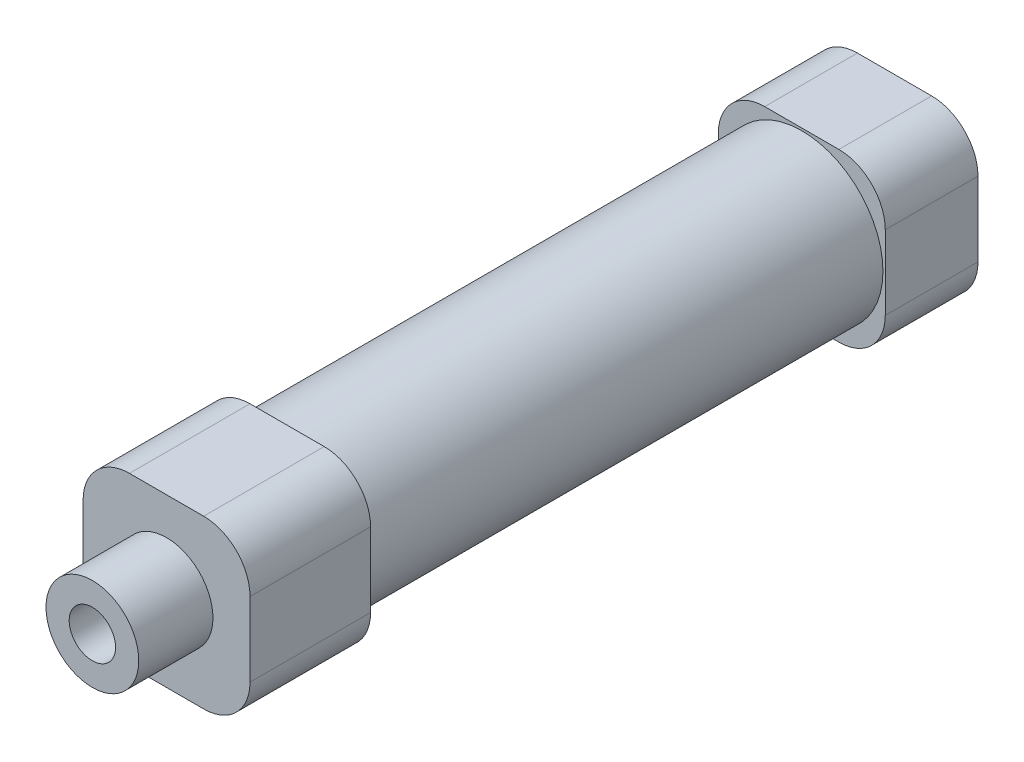
from build123d import *

# Parameters (mm, degrees)
SKETCH_1_W          = 18
SKETCH_1_H          = 18
EXTRUDE_1_DEPTH     = 10
SKETCH_2_R          = 8.75
EXTRUDE_2_DEPTH     = 55.5
SKETCH_3_W          = 18
SKETCH_3_H          = 18
EXTRUDE_3_DEPTH     = 13
SKETCH_4_R          = 5
EXTRUDE_4_DEPTH     = 8
SKETCH_5_R          = 2.5
CUT_EXTRUDE_1_DEPTH = 85.5
FILLET_1_R          = 5
CUT_EXTRUDE_2_REACH = 20
SKETCH_6_R          = 2.5


with BuildPart() as part:
    # 草图1 → 凸台-拉伸1 (new body)
    with BuildSketch(Plane.XY):
        Rectangle(SKETCH_1_W, SKETCH_1_H)
    extrude(amount=EXTRUDE_1_DEPTH)

    # 草图2 → 凸台-拉伸2 (add)
    with BuildSketch(Plane.XY.offset(10)):
        Circle(SKETCH_2_R)
    extrude(amount=EXTRUDE_2_DEPTH)

    # 草图3 → 凸台-拉伸3 (add)
    with BuildSketch(Plane.XY.offset(65.5)):
        Rectangle(SKETCH_3_W, SKETCH_3_H)
    extrude(amount=EXTRUDE_3_DEPTH)

    # 草图4 → 凸台-拉伸4 (add)
    with BuildSketch(Plane.XY.offset(78.5)):
        Circle(SKETCH_4_R)
    extrude(amount=EXTRUDE_4_DEPTH)

    # 草图5 → 切除-拉伸1 (cut)
    with BuildSketch(Plane.XY.offset(86.5)):
        Circle(SKETCH_5_R)
    extrude(amount=-CUT_EXTRUDE_1_DEPTH, mode=Mode.SUBTRACT)

    # 圆角1
    fillet_1_edges = [part.edges().sort_by_distance(p)[0] for p in [
        (9, -9, 72),
        (9, 9, 72),
        (-9, 9, 72),
        (-9, -9, 72),
        (9, -9, 5),
        (-9, -9, 5),
        (-9, 9, 5),
        (9, 9, 5),
    ]]
    fillet(fillet_1_edges, radius=FILLET_1_R)

    # 草图6 → 切除-拉伸2 (cut, up to next)
    with BuildSketch(Plane.XZ.offset(9), mode=Mode.PRIVATE) as cut_extrude_2_sk1:
        with Locations((0, 5.25)):
            Circle(SKETCH_6_R)
    cut_extrude_2_tool1 = extrude(cut_extrude_2_sk1.sketch, amount=-CUT_EXTRUDE_2_REACH, mode=Mode.PRIVATE) & part.part
    add(cut_extrude_2_tool1.solids().sort_by_distance((0, -9, 5.25))[0], mode=Mode.SUBTRACT)
    # 草图6 → 切除-拉伸2 (cut, up to next)
    with BuildSketch(Plane.XZ.offset(9), mode=Mode.PRIVATE) as cut_extrude_2_sk2:
        with Locations((0, 70.25)):
            Circle(SKETCH_6_R)
    cut_extrude_2_tool2 = extrude(cut_extrude_2_sk2.sketch, amount=-CUT_EXTRUDE_2_REACH, mode=Mode.PRIVATE) & part.part
    add(cut_extrude_2_tool2.solids().sort_by_distance((0, -9, 70.25))[0], mode=Mode.SUBTRACT)


solid = part.part
